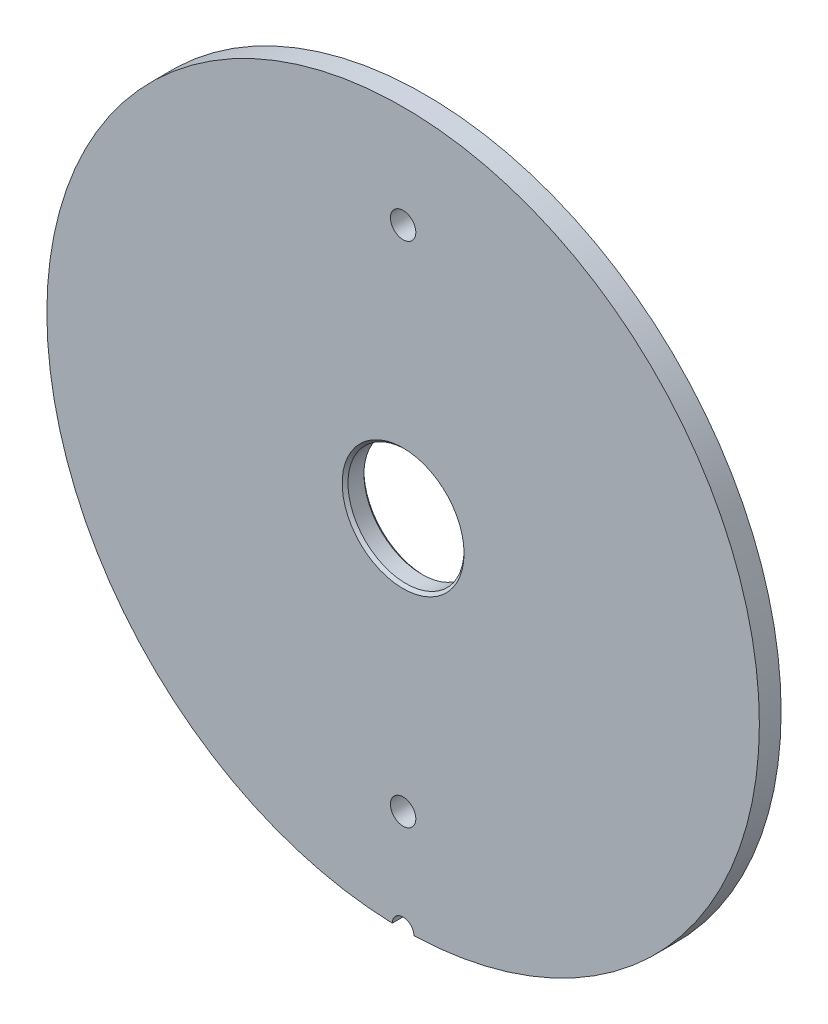
from build123d import *

# Parameters (mm, degrees)
ESQUISSE1_R             = 245.5
ESQUISSE1_R_2           = 40
BOSS_EXTRU_1_DEPTH      = 15
D_GAGEMENT_M20_D        = 17.5
D_GAGEMENT_M20_DEPTH    = 15
CHANFREIN1_SIZE         = 2
ENL_V_MAT_EXTRU_1_REACH = 17
ESQUISSE4_R             = 7.5


with BuildPart() as part:
    # Esquisse1 → Boss.-Extru.1 (new body)
    with BuildSketch(Plane.XY):
        Circle(ESQUISSE1_R)
        Circle(ESQUISSE1_R_2, mode=Mode.SUBTRACT)
    extrude(amount=BOSS_EXTRU_1_DEPTH)

    # Dégagement M20
    with Locations(Plane.XY.offset(15)):
        with Locations((0, 175), (0, -175)):
            Hole(D_GAGEMENT_M20_D / 2, depth=D_GAGEMENT_M20_DEPTH)

    # Chanfrein1
    chanfrein1_edges = [part.edges().sort_by_distance(p)[0] for p in [
        (-40, 0, 0),
        (-40, 0, 15),
    ]]
    chamfer(chanfrein1_edges, length=CHANFREIN1_SIZE)

    # Esquisse4 → Enlèv. mat.-Extru.1 (cut, up to next)
    with BuildSketch(Plane(origin=(0, 0, 0), x_dir=(-1, 0, 0), z_dir=(0, 0, -1)), mode=Mode.PRIVATE) as enl_v_mat_extru_1_sk1:
        with Locations((0, -245.5)):
            Circle(ESQUISSE4_R)
    enl_v_mat_extru_1_tool1 = extrude(enl_v_mat_extru_1_sk1.sketch, amount=-ENL_V_MAT_EXTRU_1_REACH, mode=Mode.PRIVATE) & part.part
    add(enl_v_mat_extru_1_tool1.solids().sort_by_distance((0, -245.5, 0))[0], mode=Mode.SUBTRACT)


solid = part.part
